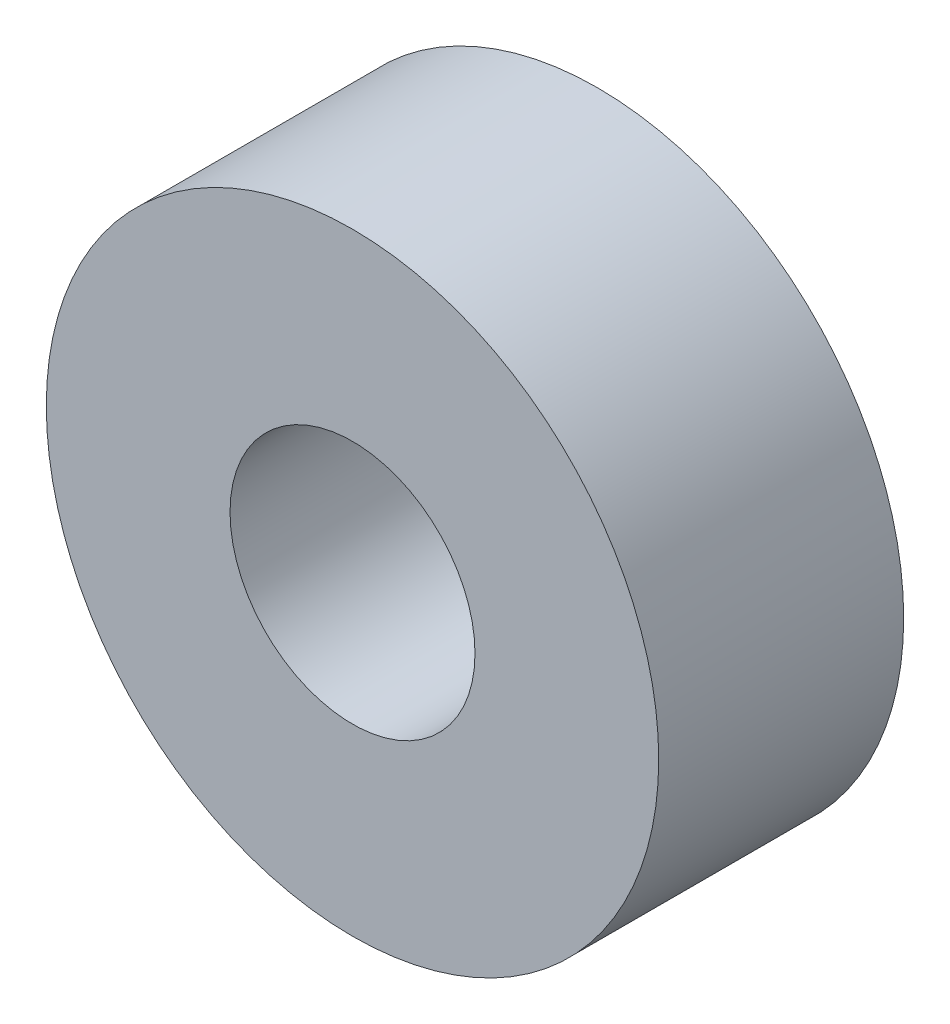
from build123d import *

# Parameters (mm, degrees)
SKETCH1_R           = 5
SKETCH1_R_2         = 2
BOSS_EXTRUDE1_DEPTH = 2


with BuildPart() as part:
    # Sketch1 → Boss-Extrude1 (new body, symmetric)
    with BuildSketch(Plane.XY):
        Circle(SKETCH1_R)
        Circle(SKETCH1_R_2, mode=Mode.SUBTRACT)
    extrude(amount=BOSS_EXTRUDE1_DEPTH, both=True)


solid = part.part
